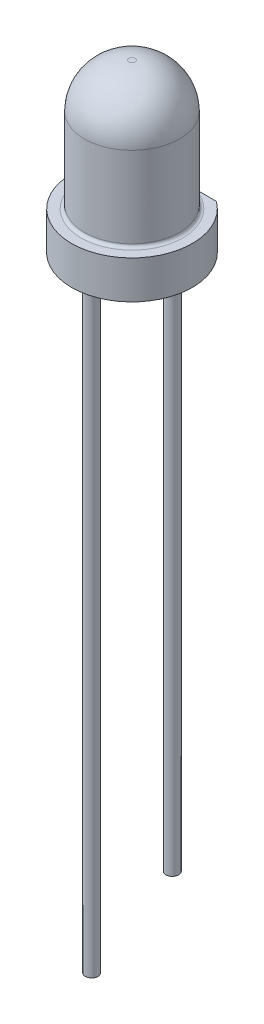
from build123d import *

# Parameters (mm, degrees)
SKETCH2_W           = 3
SKETCH2_H           = 0.5
CUT_EXTRUDE1_DEPTH  = 1.2
FILLET1_R           = 0.1
SKETCH3_R           = 0.2
BOSS_EXTRUDE1_DEPTH = 17.5
SKETCH4_R           = 0.2
BOSS_EXTRUDE2_DEPTH = 1.5


with BuildPart() as part:
    # Sketch1 → Revolve1 (revolve)
    with BuildSketch(Plane.XY):
        with BuildLine():
            Line((0, 0), (0, 5.25))
            Line((0, 5.25), (0.1, 5.25))
            ThreePointArc((0.1, 5.25), (1.089949494, 4.839949494), (1.5, 3.85))
            Line((1.5, 3.85), (1.5, 1.2))
            Line((1.5, 1.2), (1.9, 1.2))
            Line((1.9, 1.2), (1.9, 0))
            Line((1.9, 0), (0, 0))
        make_face()
    revolve(axis=Axis((0, 0, 0), (0, 1, 0)))

    # Sketch2 → Cut-Extrude1 (cut)
    with BuildSketch(Plane(origin=(0, 1.2, 0), x_dir=(1, 0, 0), z_dir=(0, 1, 0))):
        with Locations((0, 1.78)):
            Rectangle(SKETCH2_W, SKETCH2_H)
    extrude(amount=-CUT_EXTRUDE1_DEPTH, mode=Mode.SUBTRACT)

    # Fillet1
    fillet1_edges = [part.edges().sort_by_distance(p)[0] for p in [
        (1.126543386, 0.6, -1.53),
        (-1.126543386, 0.6, -1.53),
        (-1.5, 1.2, 0),
    ]]
    fillet(fillet1_edges, radius=FILLET1_R)

    # Sketch3 → Boss-Extrude1 (add)
    with BuildSketch(Plane.XZ):
        with Locations((0, 1.27)):
            Circle(SKETCH3_R)
        with Locations((0, -1.27)):
            Circle(SKETCH3_R)
    extrude(amount=BOSS_EXTRUDE1_DEPTH)

    # Sketch4 → Boss-Extrude2 (add)
    with BuildSketch(Plane.XZ.offset(17.5)):
        with Locations((0, 1.27)):
            Circle(SKETCH4_R)
    extrude(amount=BOSS_EXTRUDE2_DEPTH)


solid = part.part
